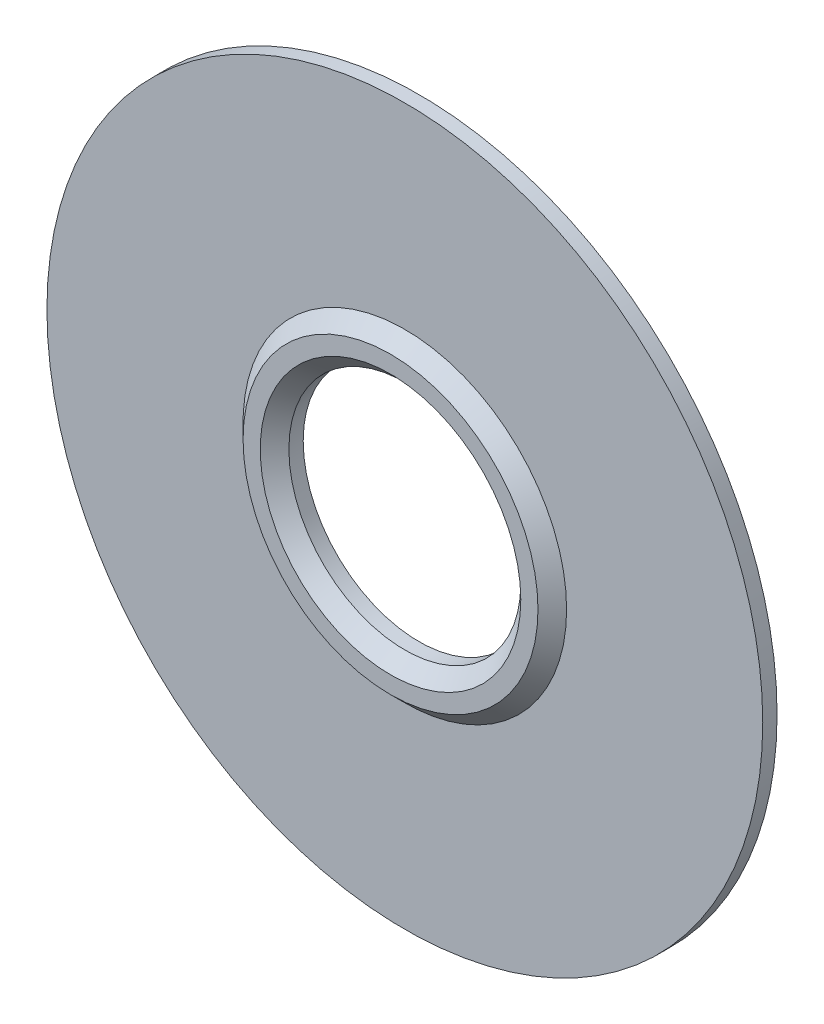
from build123d import *

# Parameters (mm, degrees)
SZKIC1_R                    = 25
SZKIC1_R_2                  = 8.1
DODANIE_WYCI_GNI_CIE1_DEPTH = 1
SZKIC2_R                    = 11.3
SZKIC2_R_2                  = 8.1
DODANIE_WYCI_GNI_CIE2_DEPTH = 1
DODANIE_WYCI_GNI_CIE2_TAPER = 45


with BuildPart() as part:
    # Szkic1 → Dodanie-wyciągnięcie1 (new body)
    with BuildSketch(Plane.XY):
        with Locations((-0.065846009, 4.978571429)):
            Circle(SZKIC1_R)
        with Locations((-0.065846009, 4.978571429)):
            Circle(SZKIC1_R_2, mode=Mode.SUBTRACT)
    extrude(amount=-DODANIE_WYCI_GNI_CIE1_DEPTH)

    # Szkic2 → Dodanie-wyciągnięcie2 (add)
    with BuildSketch(Plane.XY):
        with Locations((-0.065846009, 4.978571429)):
            Circle(SZKIC2_R)
        with Locations((-0.065846009, 4.978571429)):
            Circle(SZKIC2_R_2, mode=Mode.SUBTRACT)
    extrude(amount=DODANIE_WYCI_GNI_CIE2_DEPTH, taper=DODANIE_WYCI_GNI_CIE2_TAPER)


solid = part.part
